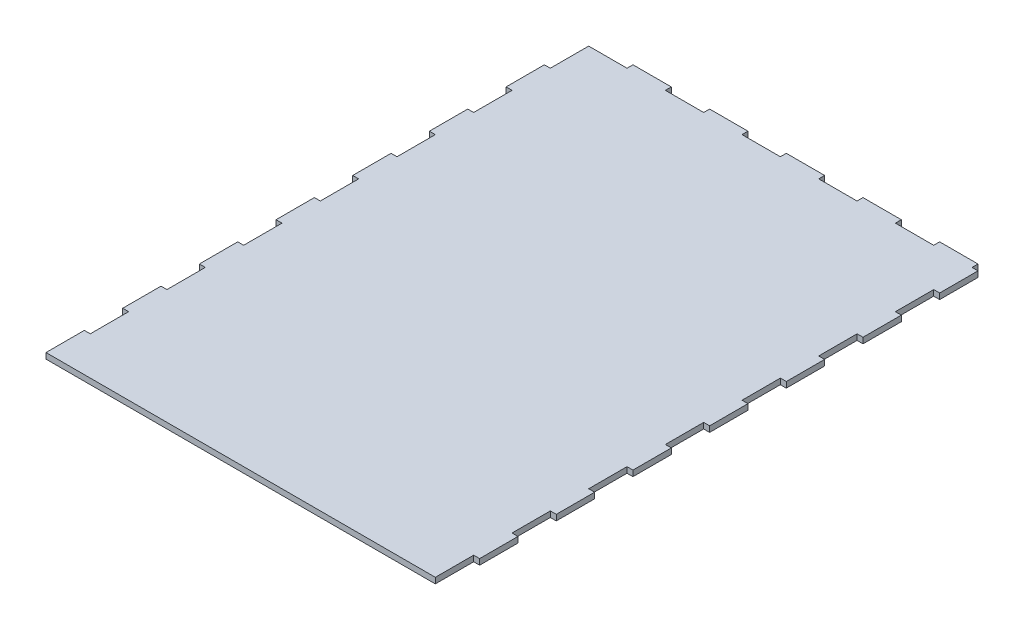
from build123d import *

# Parameters (mm, degrees)
SALIENTE_EXTRUIR1_DEPTH = 3


with BuildPart() as part:
    # Croquis1 → Saliente-Extruir1 (new body)
    with BuildSketch(Plane(origin=(0, 0, 0), x_dir=(1, 0, 0), z_dir=(0, 1, 0))):
        Polygon((0, 0), (200, 0), (200, 20), (203.1, 20), (203.1, 40), (200, 40), (200, 60), (203.1, 60), (203.1, 80), (200, 80), (200, 100), (203.1, 100), (203.1, 120), (200, 120), (200, 140), (203.1, 140), (203.1, 160), (200, 160), (200, 180), (203.1, 180), (203.1, 200), (200, 200), (200, 220), (203.1, 220), (203.1, 240), (200, 240), (200, 260), (203.1, 260), (203.1, 280), (200, 280), (200, 283.1), (180, 283.1), (180, 280), (160, 280), (160, 283.1), (140, 283.1), (140, 280), (120, 280), (120, 283.1), (100, 283.1), (100, 280), (80, 280), (80, 283.1), (60, 283.1), (60, 280), (40, 280), (40, 283.1), (20, 283.1), (20, 280), (0, 280), (0, 260), (-3.1, 260), (-3.1, 240), (0, 240), (0, 220), (-3.1, 220), (-3.1, 200), (0, 200), (0, 180), (-3.1, 180), (-3.1, 160), (0, 160), (0, 140), (-3.1, 140), (-3.1, 120), (0, 120), (0, 100), (-3.1, 100), (-3.1, 80), (0, 80), (0, 60), (-3.1, 60), (-3.1, 40), (0, 40), (0, 20), (-3.1, 20), (-3.1, 0), align=None)
    extrude(amount=SALIENTE_EXTRUIR1_DEPTH)


solid = part.part
